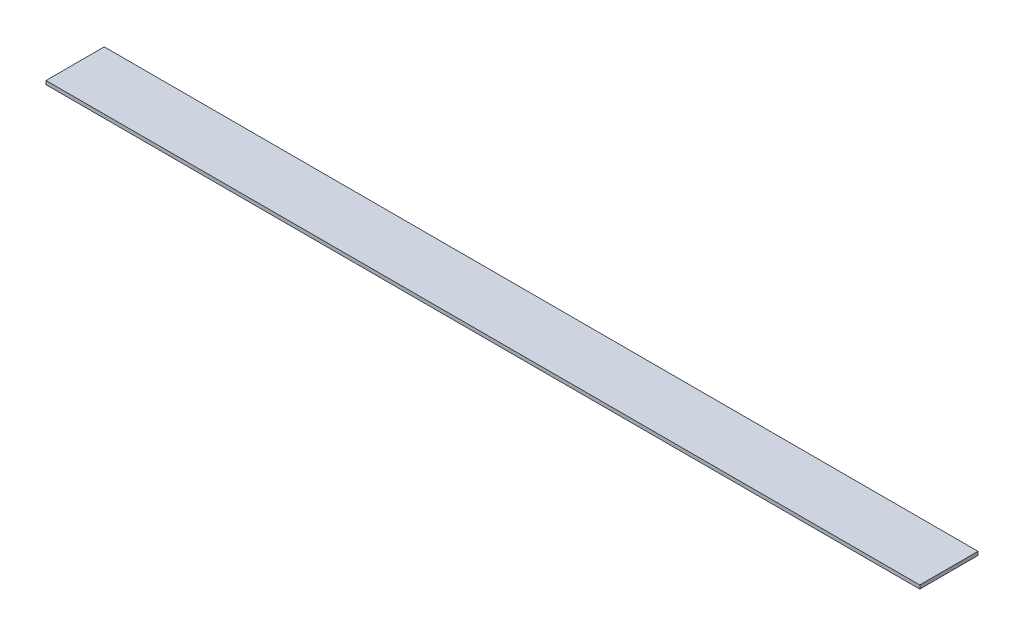
from build123d import *

# Parameters (mm, degrees)
SKETCH1_W           = 381
SKETCH1_H           = 25.4
BOSS_EXTRUDE1_DEPTH = 1.5875


with BuildPart() as part:
    # Sketch1 → Boss-Extrude1 (new body)
    with BuildSketch(Plane(origin=(0, 0, 0), x_dir=(1, 0, 0), z_dir=(0, 1, 0))):
        with Locations((190.5, 12.7)):
            Rectangle(SKETCH1_W, SKETCH1_H)
    extrude(amount=BOSS_EXTRUDE1_DEPTH)


solid = part.part
